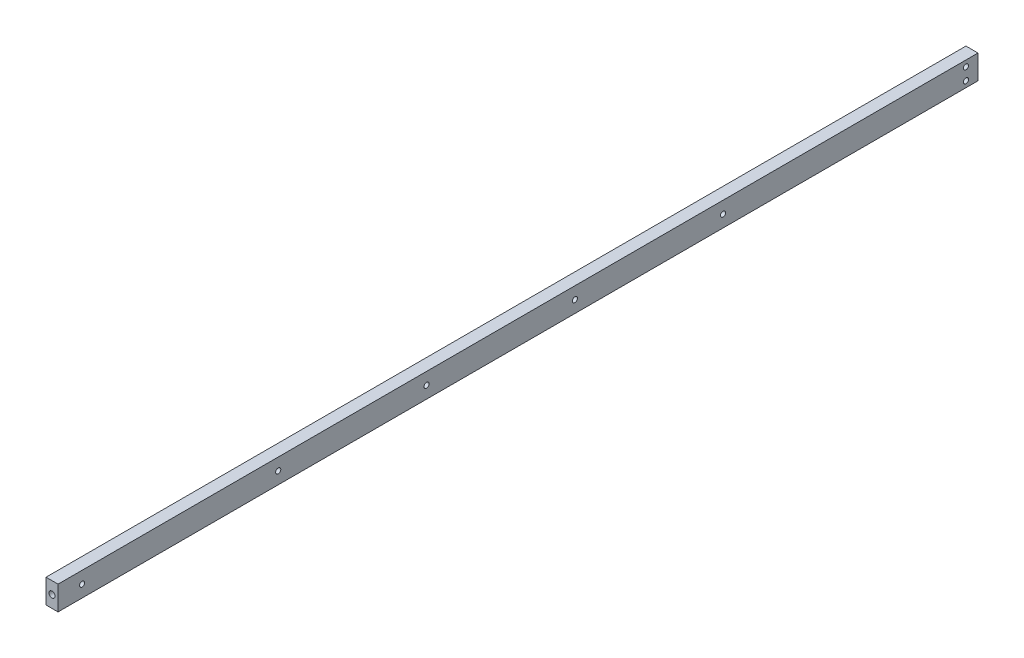
from build123d import *

# Parameters (mm, degrees)
SKETCH1_W                 = 6.35
SKETCH1_H                 = 12.7
BOSS_EXTRUDE1_DEPTH       = 485.14
TAP_DRILL_FOR_6_32_TAP2_D = 2.7051
TAP_DRILL_FOR_6_32_TAP1_D = 2.7051
SKETCH6_R                 = 1.5875
CUT_EXTRUDE1_DEPTH        = 6.35
TAP_DRILL_FOR_6_32_TAP4_D = 2.7051


with BuildPart() as part:
    # Sketch1 → Boss-Extrude1 (new body)
    with BuildSketch(Plane.XY):
        with Locations((3.175, 6.35)):
            Rectangle(SKETCH1_W, SKETCH1_H)
    extrude(amount=BOSS_EXTRUDE1_DEPTH)

    # Tap Drill for #6-32 Tap2 (through all)
    with Locations(Plane(origin=(6.35, 0, 0), x_dir=(0, 0, -1), z_dir=(1, 0, 0))):
        with Locations((-6.35, 3.175), (-6.35, 9.525)):
            Hole(TAP_DRILL_FOR_6_32_TAP2_D / 2)

    # Tap Drill for #6-32 Tap1 (through all)
    with Locations(Plane(origin=(6.35, 0, 0), x_dir=(0, 0, -1), z_dir=(1, 0, 0))):
        with Locations((-472.44, 6.35)):
            Hole(TAP_DRILL_FOR_6_32_TAP1_D / 2)

    # Sketch6 → Cut-Extrude1 (cut)
    with BuildSketch(Plane.XY.offset(485.14)):
        with Locations((3.175, 6.35)):
            Circle(SKETCH6_R)
    extrude(amount=-CUT_EXTRUDE1_DEPTH, mode=Mode.SUBTRACT)

    # Tap Drill for #6-32 Tap4 (through all)
    with Locations(Plane(origin=(-13.49375, 1342.118435602, -1739.809386822), x_dir=(0, 0, -1), z_dir=(-1, 0, 0))):
        with Locations((-2108.842826276, 1335.768435602), (-1952.378826276, 1335.768435602), (-2030.610826276, 1335.768435602), (-1874.240025135, 1335.768435602)):
            Hole(TAP_DRILL_FOR_6_32_TAP4_D / 2)


solid = part.part
